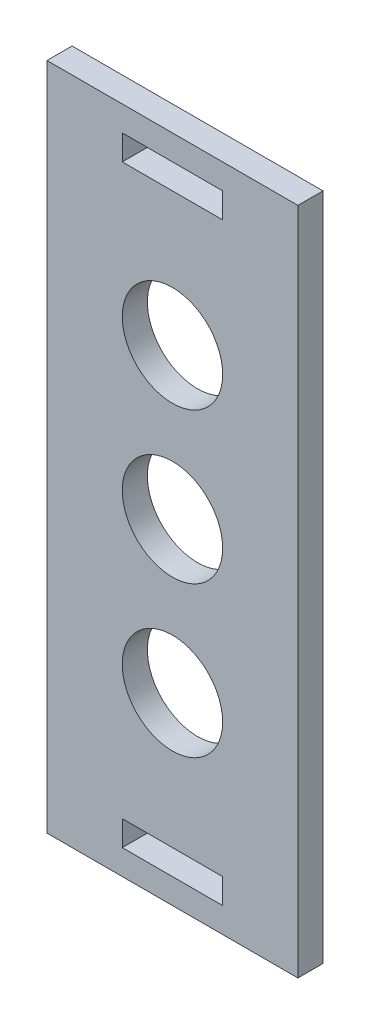
from build123d import *

# Parameters (mm, degrees)
SKETCH_1_W      = 30
SKETCH_1_H      = 80
SKETCH_1_R      = 6
SKETCH_1_W_2    = 12
SKETCH_1_H_2    = 3
EXTRUDE_1_DEPTH = 3


with BuildPart() as part:
    # 草图1 → 凸台-拉伸1 (new body)
    with BuildSketch(Plane.XY):
        with Locations((630.693975789, 351.419851644)):
            Rectangle(SKETCH_1_W, SKETCH_1_H)
        with Locations((630.693975789, 351.419851644)):
            Circle(SKETCH_1_R, mode=Mode.SUBTRACT)
        with Locations((630.693975789, 369.419851644)):
            Circle(SKETCH_1_R, mode=Mode.SUBTRACT)
        with Locations((630.693975789, 333.419851644)):
            Circle(SKETCH_1_R, mode=Mode.SUBTRACT)
        with Locations((630.693975789, 315.919851644)):
            Rectangle(SKETCH_1_W_2, SKETCH_1_H_2, mode=Mode.SUBTRACT)
        with Locations((630.693975789, 386.919851644)):
            Rectangle(SKETCH_1_W_2, SKETCH_1_H_2, mode=Mode.SUBTRACT)
    extrude(amount=EXTRUDE_1_DEPTH)


solid = part.part
